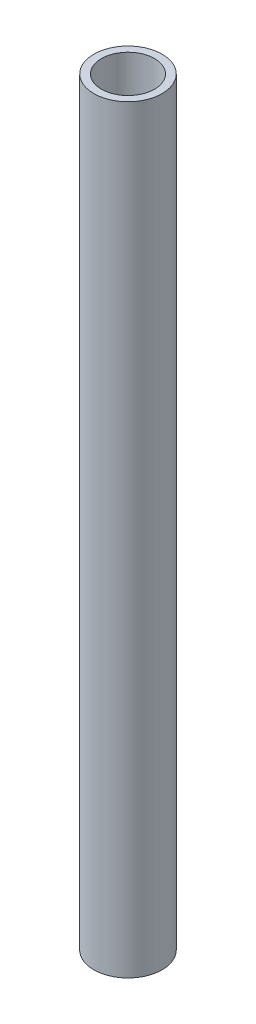
from build123d import *

# Parameters (mm, degrees)
ESQUISSE1_R        = 9
ESQUISSE1_R_2      = 7
BOSS_EXTRU_1_DEPTH = 200


with BuildPart() as part:
    # Esquisse1 → Boss.-Extru.1 (new body)
    with BuildSketch(Plane(origin=(0, 0, 0), x_dir=(1, 0, 0), z_dir=(0, 1, 0))):
        Circle(ESQUISSE1_R)
        Circle(ESQUISSE1_R_2, mode=Mode.SUBTRACT)
    extrude(amount=BOSS_EXTRU_1_DEPTH)


solid = part.part
